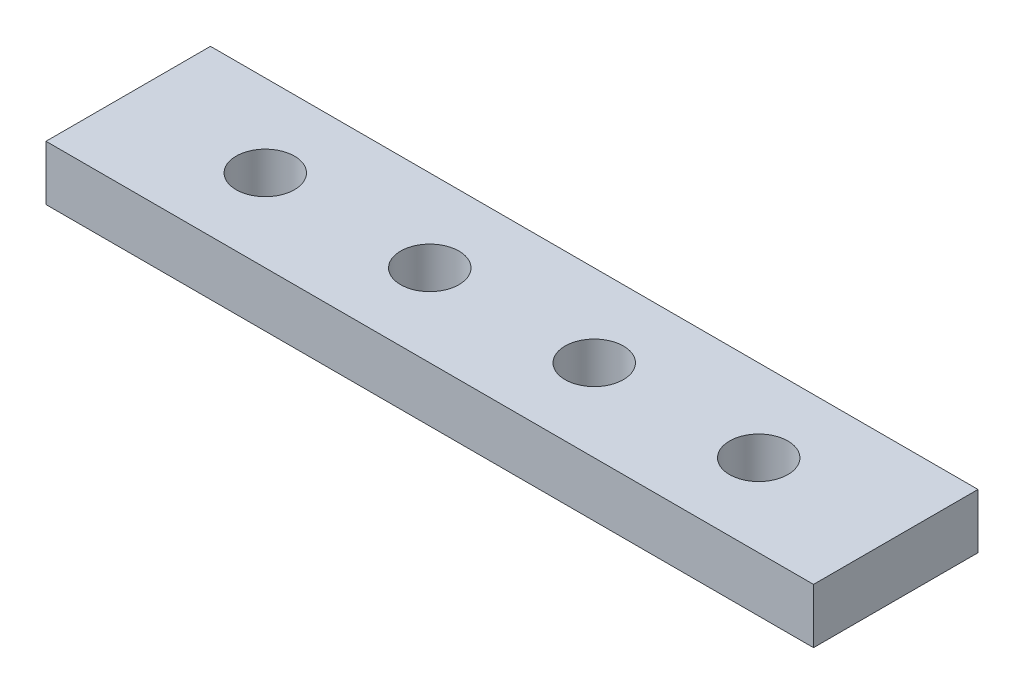
from build123d import *

# Parameters (mm, degrees)
SKETCH1_W               = 88.9
SKETCH1_H               = 19.05
BOSS_EXTRUDE1_DEPTH     = 6.35
F_1_4_CLEARANCE_HOLE1_D = 6.7564


with BuildPart() as part:
    # Sketch1 → Boss-Extrude1 (new body)
    with BuildSketch(Plane(origin=(0, 0, 0), x_dir=(1, 0, 0), z_dir=(0, 1, 0))):
        Rectangle(SKETCH1_W, SKETCH1_H)
    extrude(amount=BOSS_EXTRUDE1_DEPTH)

    # 1/4 Clearance Hole1 (through all)
    with Locations(Plane(origin=(0, 0, 0), x_dir=(-1, 0, 0), z_dir=(0, -1, 0))):
        with Locations((-28.575, 0), (28.575, 0), (9.525, 0), (-9.525, 0)):
            Hole(F_1_4_CLEARANCE_HOLE1_D / 2)


solid = part.part
